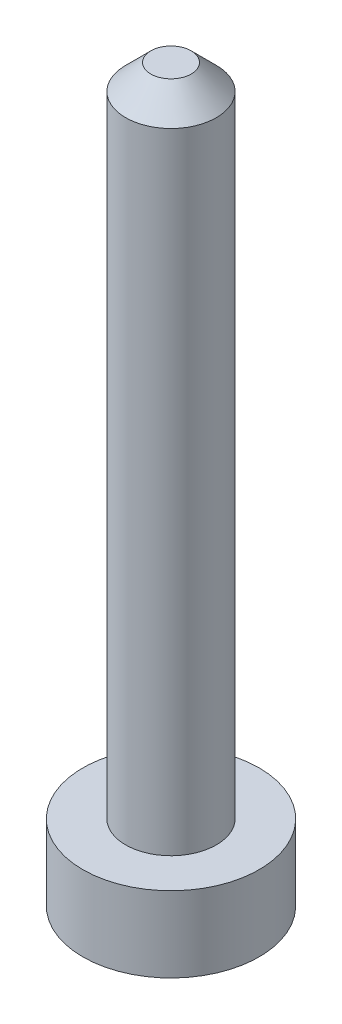
from build123d import *

# Parameters (mm, degrees)
SKETCH_1_R      = 3.5
EXTRUDE_1_DEPTH = 3
SKETCH_1_3_R    = 1.8
EXTRUDE_2_DEPTH = 26
CHAMFER_1_SIZE  = 1


with BuildPart() as part:
    # Эскиз1 → Бобышка-Вытянуть1 (new body)
    with BuildSketch(Plane(origin=(0, 0, 0), x_dir=(1, 0, 0), z_dir=(0, 1, 0))):
        Circle(SKETCH_1_R)
    extrude(amount=-EXTRUDE_1_DEPTH)

    # Эскиз1<3> → Бобышка-Вытянуть2 (add)
    with BuildSketch(Plane(origin=(0, 0, 0), x_dir=(1, 0, 0), z_dir=(0, 1, 0))):
        Circle(SKETCH_1_3_R)
    extrude(amount=EXTRUDE_2_DEPTH)

    # Фаска1
    chamfer_1_edges = [part.edges().sort_by_distance(p)[0] for p in [
        (-1.8, 26, 0),
    ]]
    chamfer(chamfer_1_edges, length=CHAMFER_1_SIZE)


solid = part.part
